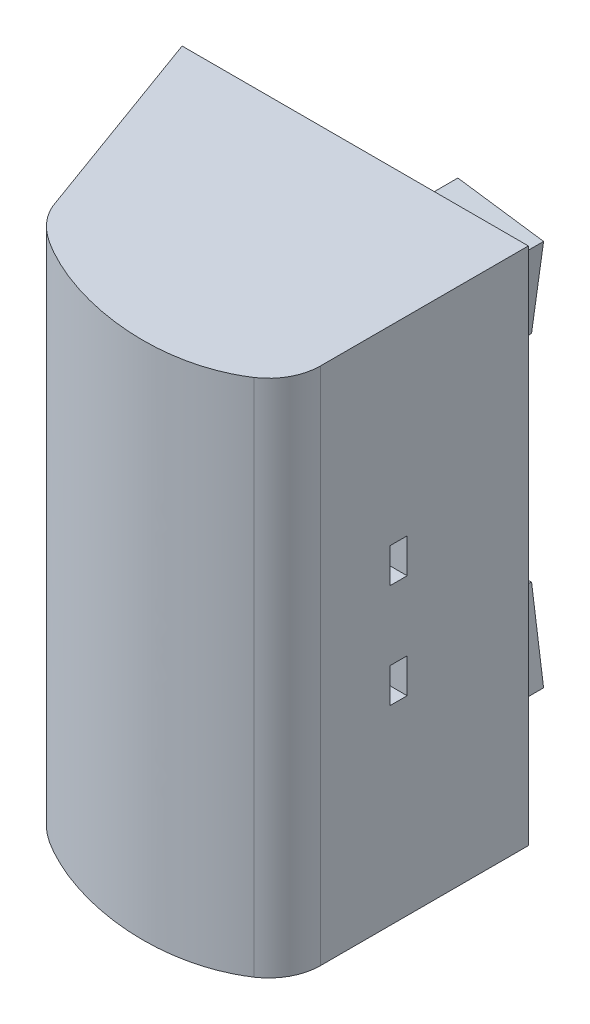
from build123d import *

# Parameters (mm, degrees)
BOSS_EXTRUDE1_DEPTH = 60
SKETCH2_R           = 1.6
CUT_EXTRUDE1_DEPTH  = 20
SKETCH4_W           = 2
SKETCH4_H           = 4
CUT_EXTRUDE2_DEPTH  = 10
BOSS_EXTRUDE2_DEPTH = 9


with BuildPart() as part:
    # Sketch1 → Boss-Extrude1 (new body)
    with BuildSketch(Plane(origin=(0, 0, 0), x_dir=(1, 0, 0), z_dir=(0, 1, 0))):
        with BuildLine():
            Line((40, 0), (0, 0))
            Line((0, 0), (8.550503583, -23.49231552))
            add(Edge.make_bspline(
                [(8.550503583, -23.49231552), (9.187650747, -24.984982914), (10.869033495, -26.695868857), (13.579943454, -28.275526589), (21.375498678, -32.059284682), (31.165356306, -32.945912064), (37.204636828, -29.076990777)],
                knots=[0, 0, 0, 0, 0.15219933, 0.226855665, 0.301953476, 0.995167611, 0.995167611, 0.995167611, 0.995167611], degree=3))
            add(Edge.make_bspline(
                [(37.204636828, -29.076990777), (37.246736594, -29.050020564), (37.288700602, -29.022823469), (37.330527165, -28.995398615)],
                knots=[0.995167611, 0.995167611, 0.995167611, 0.995167611, 1, 1, 1, 1], degree=3))
            ThreePointArc((37.330527165, -28.995398615), (39.290627696, -26.837555683), (40, -24.01))
            Line((40, -24.01), (40, 0))
        make_face()
    extrude(amount=BOSS_EXTRUDE1_DEPTH)

    # Sketch2 → Cut-Extrude1 (cut)
    with BuildSketch(Plane(origin=(0, 0, 0), x_dir=(-1, 0, 0), z_dir=(0, 0, -1))):
        with Locations((-34, 36)):
            Circle(SKETCH2_R)
        with Locations((-34, 24)):
            Circle(SKETCH2_R)
    extrude(amount=-CUT_EXTRUDE1_DEPTH, mode=Mode.SUBTRACT)

    # Sketch4 → Cut-Extrude2 (cut)
    with BuildSketch(Plane(origin=(40, 0, 0), x_dir=(0, 0, -1), z_dir=(1, 0, 0))):
        with Locations((-15, 24)):
            Rectangle(SKETCH4_W, SKETCH4_H)
        with Locations((-15, 36)):
            Rectangle(SKETCH4_W, SKETCH4_H)
    extrude(amount=-CUT_EXTRUDE2_DEPTH, mode=Mode.SUBTRACT)

    # Sketch5 → Boss-Extrude2 (add)
    with BuildSketch(Plane(origin=(0, 0, 0), x_dir=(-1, 0, 0), z_dir=(0, 0, -1))):
        Polygon((-31.369100365, 42.428714266), (-32.760831375, 52.331394953), (-22.858150687, 53.723125963), (-21.466419678, 43.820445275), align=None)
        Polygon((-31.369100365, 17.571285734), (-32.760831375, 7.668605047), (-22.858150687, 6.276874037), (-21.466419678, 16.179554725), align=None)
    extrude(amount=BOSS_EXTRUDE2_DEPTH)

    # Sketch6 → Revolve1 (revolve)
    with BuildSketch(Plane(origin=(34, 0, 0), x_dir=(0, 0, -1), z_dir=(1, 0, 0))):
        Polygon((0, 37.6), (2, 37.6), (0, 38.6), align=None)
    revolve(axis=Axis((34, 36, 0), (0, 0, -1)))

    # Sketch7 → Revolve2 (revolve)
    with BuildSketch(Plane(origin=(34, 0, 0), x_dir=(0, 0, -1), z_dir=(1, 0, 0))):
        Polygon((0, 25.6), (2, 25.6), (0, 26.6), align=None)
    revolve(axis=Axis((34, 24, 0), (0, 0, -1)))


solid = part.part
